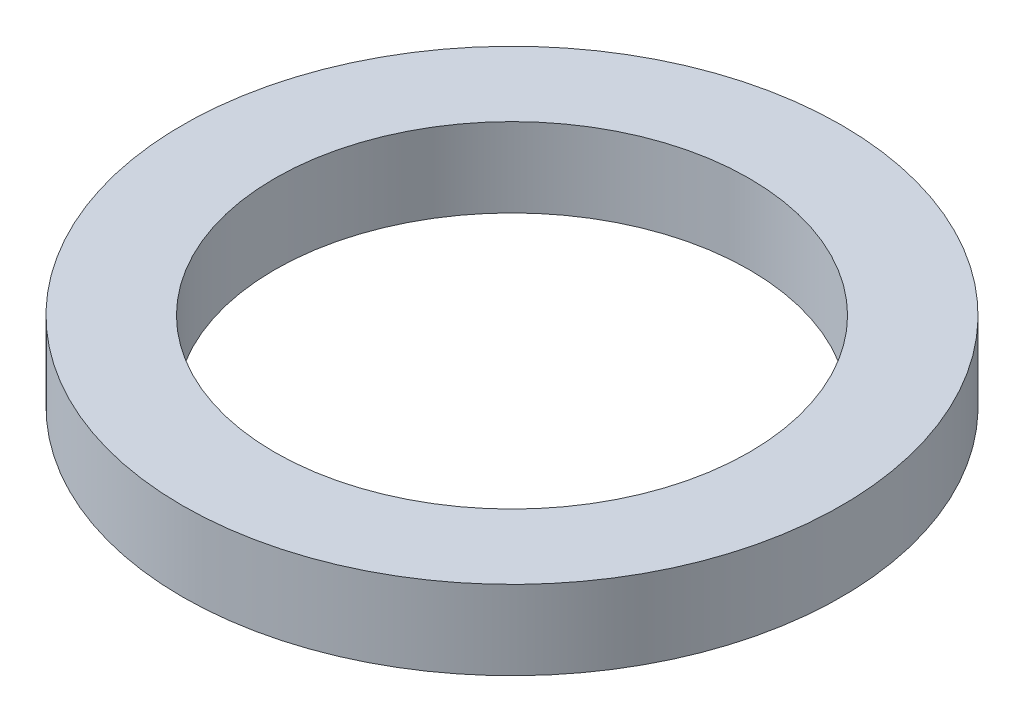
from build123d import *

# Parameters (mm, degrees)
SKETCH_1_R      = 5
SKETCH_1_R_2    = 3.6
EXTRUDE_1_DEPTH = 1.2


with BuildPart() as part:
    # 草图1 → 凸台-拉伸1 (new body)
    with BuildSketch(Plane(origin=(0, 0, 0), x_dir=(1, 0, 0), z_dir=(0, 1, 0))):
        Circle(SKETCH_1_R)
        Circle(SKETCH_1_R_2, mode=Mode.SUBTRACT)
    extrude(amount=EXTRUDE_1_DEPTH)


solid = part.part
